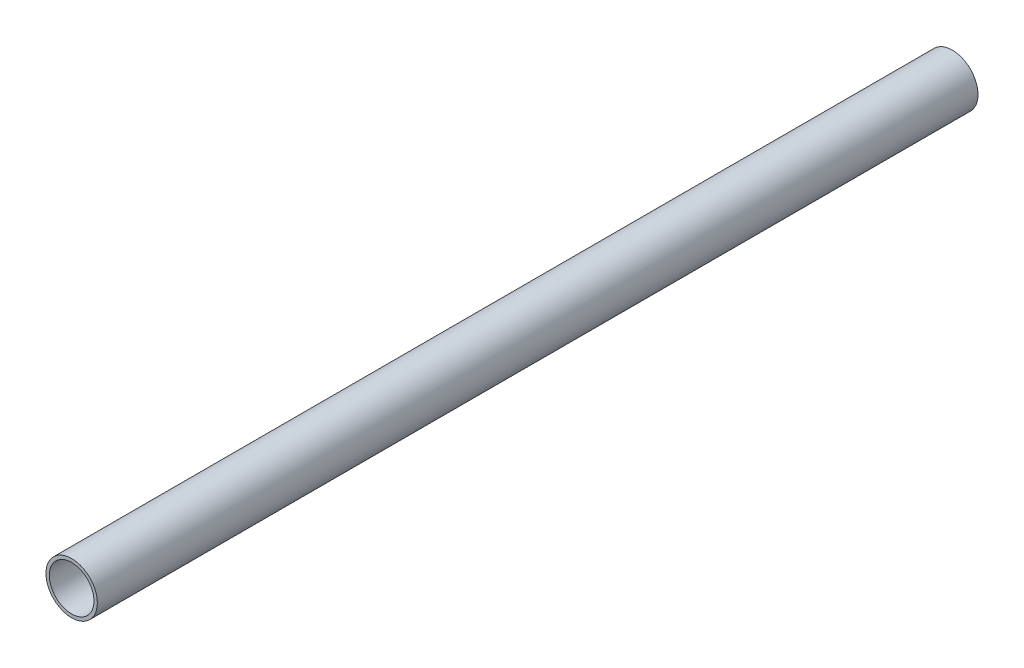
from build123d import *

# Parameters (mm, degrees)
SKETCH1_R           = 44.45
SKETCH1_R_2         = 38.6334
BOSS_EXTRUDE1_DEPTH = 1524


with BuildPart() as part:
    # Sketch1 → Boss-Extrude1 (new body)
    with BuildSketch(Plane.XY):
        Circle(SKETCH1_R)
        Circle(SKETCH1_R_2, mode=Mode.SUBTRACT)
    extrude(amount=BOSS_EXTRUDE1_DEPTH)


solid = part.part
